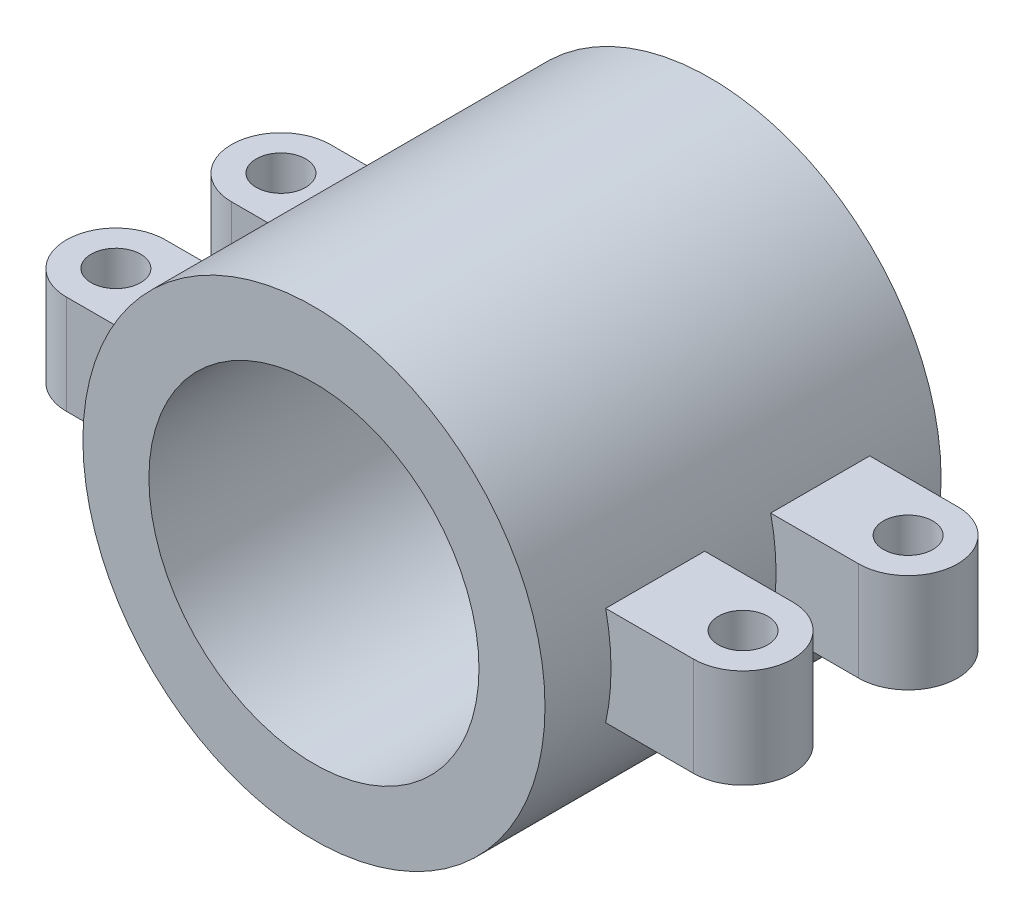
from build123d import *

# Parameters (mm, degrees)
SKETCH_1_R               = 70
EXTRUDE_1_DEPTH          = 120
SKETCH_3_R               = 50
CUT_EXTRUDE_1_DEPTH      = 121
EXTRUDE_2_DEPTH          = 15
SKETCH_5_R               = 7.5
CUT_EXTRUDE_2_DEPTH      = 71
CUT_EXTRUDE_2_DEPTH_BACK = 71
SKETCH_6_R               = 50
CUT_EXTRUDE_3_DEPTH      = 121


with BuildPart() as part:
    # 스케치1 → 보스-돌출1 (new body)
    with BuildSketch(Plane.XY):
        Circle(SKETCH_1_R)
    extrude(amount=EXTRUDE_1_DEPTH)

    # 스케치3 → 컷-돌출1 (cut, through all)
    with BuildSketch(Plane.XY):
        Circle(SKETCH_3_R)
    extrude(amount=CUT_EXTRUDE_1_DEPTH, mode=Mode.SUBTRACT)

    # 스케치4 → 보스-돌출2 (add, symmetric)
    with BuildSketch(Plane(origin=(0, 0, 0), x_dir=(1, 0, 0), z_dir=(0, 1, 0))):
        with BuildLine():
            Line((-95, -20), (95, -20))
            ThreePointArc((95, -20), (110, -35), (95, -50))
            Line((95, -50), (-95, -50))
            ThreePointArc((-95, -50), (-110, -35), (-95, -20))
        make_face()
        with BuildLine():
            Line((-95, -100), (95, -100))
            ThreePointArc((95, -100), (110, -85), (95, -70))
            Line((95, -70), (-95, -70))
            ThreePointArc((-95, -70), (-110, -85), (-95, -100))
        make_face()
    extrude(amount=EXTRUDE_2_DEPTH, both=True)

    # 스케치5 → 컷-돌출2 (cut, two sides)
    with BuildSketch(Plane(origin=(0, 0, 0), x_dir=(1, 0, 0), z_dir=(0, 1, 0))) as cut_extrude_2_sk:
        with Locations((95, -35)):
            Circle(SKETCH_5_R)
        with Locations((95, -85)):
            Circle(SKETCH_5_R)
        with Locations((-95, -35)):
            Circle(SKETCH_5_R)
        with Locations((-95, -85)):
            Circle(SKETCH_5_R)
    extrude(amount=CUT_EXTRUDE_2_DEPTH, mode=Mode.SUBTRACT)
    extrude(cut_extrude_2_sk.sketch, amount=-CUT_EXTRUDE_2_DEPTH_BACK, mode=Mode.SUBTRACT)

    # 스케치6 → 컷-돌출3 (cut, through all)
    with BuildSketch(Plane.XY):
        Circle(SKETCH_6_R)
    extrude(amount=CUT_EXTRUDE_3_DEPTH, mode=Mode.SUBTRACT)


solid = part.part
